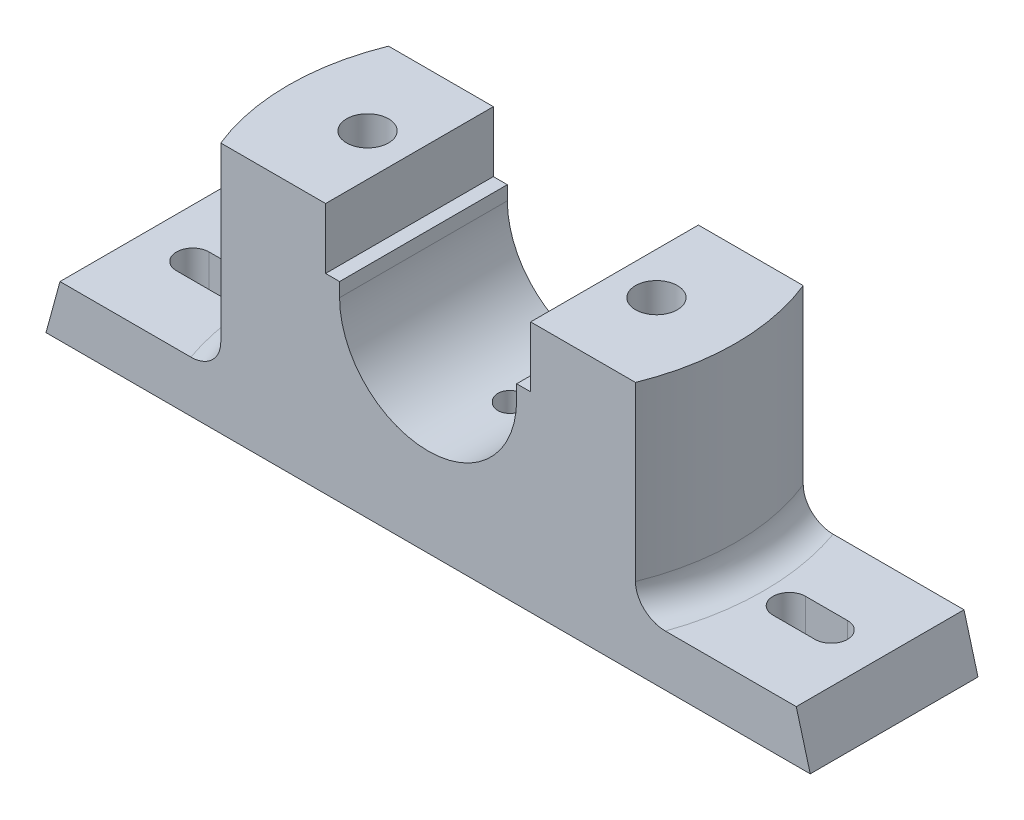
from build123d import *

# Parameters (mm, degrees)
BOSS_EXTRUDE1_DEPTH       = 18
CUT_EXTRUDE1_DEPTH        = 43
CUT_EXTRUDE2_DEPTH        = 12
SKETCH6_W                 = 20
SKETCH6_H                 = 20
CUT_EXTRUDE3_DEPTH        = 8
SKETCH7_R                 = 4.5
CUT_EXTRUDE4_DEPTH        = 47
FILLET1_R                 = 6
F_6_0MM_DOWEL_HOLE1_D     = 6
F_6_0MM_DOWEL_HOLE1_DEPTH = 6
F_6_0MM_DOWEL_HOLE1_TIP   = 1.802581857


with BuildPart() as part:
    # Sketch1 → Boss-Extrude1 (new body, symmetric)
    with BuildSketch(Plane.XY):
        with BuildLine():
            Line((82, 0), (-82, 0))
            Line((-82, 0), (-79, 11))
            Line((-79, 11), (-50, 11))
            Line((-50, 11), (-50, 54))
            Line((-50, 54), (-22, 54))
            Line((-22, 54), (-22, 41))
            Line((-22, 41), (-19, 41))
            Line((-19, 41), (-19, 38))
            ThreePointArc((-19, 38), (0, 19), (19, 38))
            Line((19, 38), (19, 41))
            Line((19, 41), (22, 41))
            Line((22, 41), (22, 54))
            Line((22, 54), (50, 54))
            Line((50, 54), (50, 11))
            Line((50, 11), (79, 11))
            Line((79, 11), (82, 0))
        make_face()
    extrude(amount=BOSS_EXTRUDE1_DEPTH, both=True)

    # Sketch2 → Cut-Extrude1 (cut)
    with BuildSketch(Plane(origin=(0, 54, 0), x_dir=(1, 0, 0), z_dir=(0, 1, 0))):
        with BuildLine():
            Line((-44.497190923, -18), (-50, -18))
            Line((-50, -18), (-50, 18))
            Line((-50, 18), (-44.497190923, 18))
            ThreePointArc((-44.497190923, 18), (-48, 0), (-44.497190923, -18))
        make_face()
        with BuildLine():
            Line((50, 18), (44.497190923, 18))
            ThreePointArc((44.497190923, 18), (48, 0), (44.497190923, -18))
            Line((44.497190923, -18), (50, -18))
            Line((50, -18), (50, 18))
        make_face()
    extrude(amount=-CUT_EXTRUDE1_DEPTH, mode=Mode.SUBTRACT)

    # Sketch4 → Cut-Extrude2 (cut, through all)
    with BuildSketch(Plane(origin=(0, 11, 0), x_dir=(1, 0, 0), z_dir=(0, 1, 0))):
        with BuildLine():
            Line((-59.5, -3.5), (-68.5, -3.5))
            ThreePointArc((-68.5, -3.5), (-72, 0), (-68.5, 3.5))
            Line((-68.5, 3.5), (-59.5, 3.5))
            ThreePointArc((-59.5, 3.5), (-56, 0), (-59.5, -3.5))
        make_face()
    cut_extrude2 = extrude(amount=-CUT_EXTRUDE2_DEPTH, mode=Mode.SUBTRACT)

    # Sketch6 → Cut-Extrude3 (cut)
    with BuildSketch(Plane.XZ):
        with Locations((-31, 0)):
            Rectangle(SKETCH6_W, SKETCH6_H)
    cut_extrude3 = extrude(amount=-CUT_EXTRUDE3_DEPTH, mode=Mode.SUBTRACT)

    # Sketch7 → Cut-Extrude4 (cut, through all)
    with BuildSketch(Plane.XZ.offset(-8)):
        with Locations(Location((-31, 0, 0), (0, 0, 270))):  # turned: the seam where the file's is
            Circle(SKETCH7_R)
    cut_extrude4 = extrude(amount=-CUT_EXTRUDE4_DEPTH, mode=Mode.SUBTRACT)

    # Fillet1
    fillet1_edges = [part.edges().sort_by_distance(p)[0] for p in [
        (48, 11, 0),
        (-48, 11, 0),
    ]]
    fillet(fillet1_edges, radius=FILLET1_R)

    # Mirror6: Cut-Extrude2, Cut-Extrude3, Cut-Extrude4 across plane
    add(cut_extrude2.mirror(Plane(origin=(0, 0, 0), x_dir=(0, 0, 1), z_dir=(1, 0, 0))), mode=Mode.SUBTRACT)
    add(cut_extrude3.mirror(Plane(origin=(0, 0, 0), x_dir=(0, 0, 1), z_dir=(1, 0, 0))), mode=Mode.SUBTRACT)
    add(cut_extrude4.mirror(Plane(origin=(0, 0, 0), x_dir=(0, 0, 1), z_dir=(1, 0, 0))), mode=Mode.SUBTRACT)

    # Ø6.0mm Dowel Hole1
    with Locations(Plane(origin=(0, 19, 0), x_dir=(1, 0, 0), z_dir=(0, 1, 0))):
        with Locations((0, 0)):
            Hole(F_6_0MM_DOWEL_HOLE1_D / 2, depth=F_6_0MM_DOWEL_HOLE1_DEPTH)
            with Locations((0, 0, -(F_6_0MM_DOWEL_HOLE1_DEPTH + F_6_0MM_DOWEL_HOLE1_TIP / 2))):  # 118° drill point
                Cone(0, F_6_0MM_DOWEL_HOLE1_D / 2, F_6_0MM_DOWEL_HOLE1_TIP, mode=Mode.SUBTRACT)


solid = part.part
